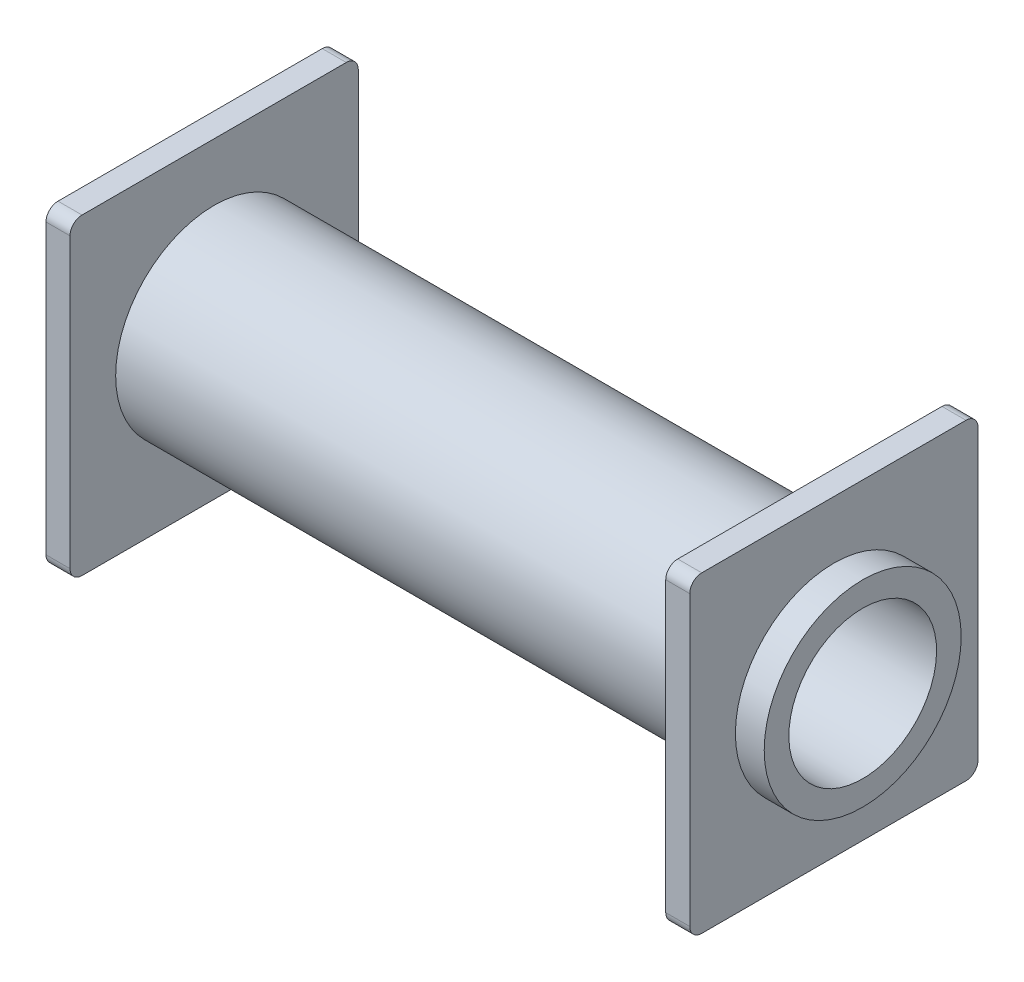
from build123d import *

# Parameters (mm, degrees)
CROQUIS1_W              = 28
CROQUIS1_H              = 4.1
CROQUIS3_W              = 12
CROQUIS3_H              = 13
SALIENTE_EXTRUIR1_DEPTH = 1
CROQUIS4_W              = 12
CROQUIS4_H              = 13
SALIENTE_EXTRUIR2_DEPTH = 1
REDONDEO1_R             = 0.5
CORTAR_EXTRUIR1_REACH   = 30
CROQUIS5_R              = 3.075


with BuildPart() as part:
    # Croquis1 → Revolución1 (revolve)
    with BuildSketch(Plane.XY):
        with Locations((0, 2.05)):
            Rectangle(CROQUIS1_W, CROQUIS1_H)
    revolve(axis=Axis((-14, 0, 0), (1, 0, 0)))

    # Croquis3 → Saliente-Extruir1 (add)
    with BuildSketch(Plane(origin=(11.8, 0, 0), x_dir=(0, 0, -1), z_dir=(1, 0, 0))):
        Rectangle(CROQUIS3_W, CROQUIS3_H)
    extrude(amount=SALIENTE_EXTRUIR1_DEPTH)

    # Croquis4 → Saliente-Extruir2 (add)
    with BuildSketch(Plane.ZY.offset(14)):
        Rectangle(CROQUIS4_W, CROQUIS4_H)
    extrude(amount=-SALIENTE_EXTRUIR2_DEPTH)

    # Redondeo1
    redondeo1_edges = [part.edges().sort_by_distance(p)[0] for p in [
        (12.3, 6.5, 6),
        (12.3, -6.5, 6),
        (12.3, -6.5, -6),
        (12.3, 6.5, -6),
        (-13.5, -6.5, -6),
        (-13.5, 6.5, -6),
        (-13.5, 6.5, 6),
        (-13.5, -6.5, 6),
    ]]
    fillet(redondeo1_edges, radius=REDONDEO1_R)

    # Croquis5 → Cortar-Extruir1 (cut, up to next)
    with BuildSketch(Plane(origin=(14, 0, 0), x_dir=(0, 0, -1), z_dir=(1, 0, 0)), mode=Mode.PRIVATE) as cortar_extruir1_sk1:
        Circle(CROQUIS5_R)
    cortar_extruir1_tool1 = extrude(cortar_extruir1_sk1.sketch, amount=-CORTAR_EXTRUIR1_REACH, mode=Mode.PRIVATE) & part.part
    add(cortar_extruir1_tool1.solids().sort_by_distance((14, 0, 0))[0], mode=Mode.SUBTRACT)


solid = part.part
